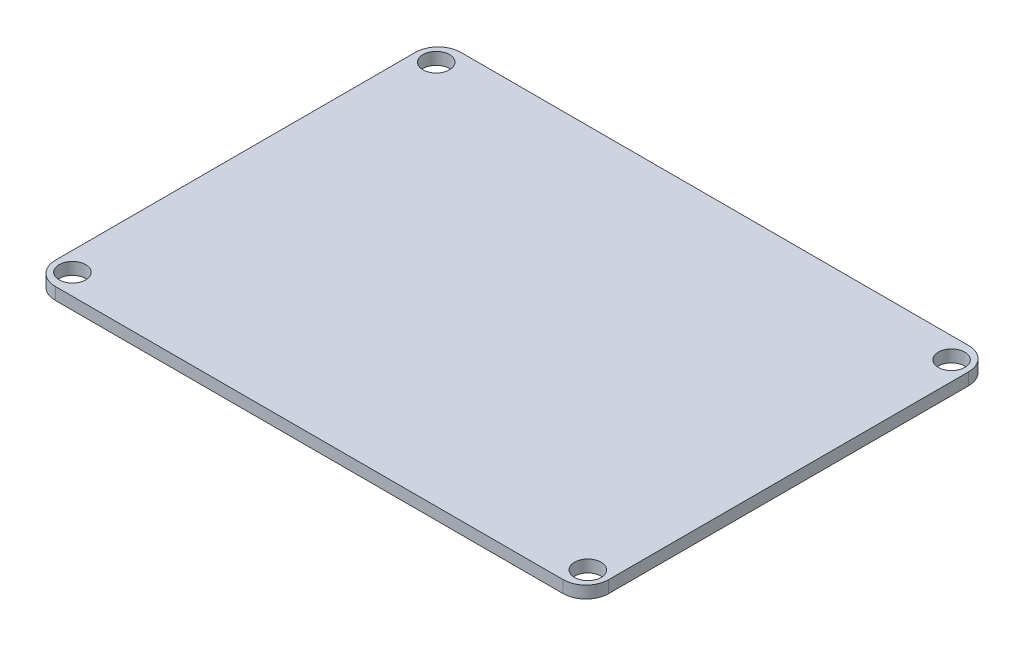
from build123d import *

# Parameters (mm, degrees)
SKETCH1_W           = 73
SKETCH1_H           = 53.5
SKETCH1_R           = 1.75
BOSS_EXTRUDE1_DEPTH = 1.6
FILLET1_R           = 3


with BuildPart() as part:
    # Sketch1 → Boss-Extrude1 (new body)
    with BuildSketch(Plane(origin=(0, 0, 0), x_dir=(1, 0, 0), z_dir=(0, 1, 0))):
        Rectangle(SKETCH1_W, SKETCH1_H)
        with Locations((-34, 24)):
            Circle(SKETCH1_R, mode=Mode.SUBTRACT)
        with Locations((34, 24)):
            Circle(SKETCH1_R, mode=Mode.SUBTRACT)
        with Locations((34, -24)):
            Circle(SKETCH1_R, mode=Mode.SUBTRACT)
        with Locations((-34, -24)):
            Circle(SKETCH1_R, mode=Mode.SUBTRACT)
    extrude(amount=BOSS_EXTRUDE1_DEPTH)

    # Fillet1
    fillet1_edges = [part.edges().sort_by_distance(p)[0] for p in [
        (-36.5, 0.8, -26.75),
        (36.5, 0.8, -26.75),
        (36.5, 0.8, 26.75),
        (-36.5, 0.8, 26.75),
    ]]
    fillet(fillet1_edges, radius=FILLET1_R)


solid = part.part
